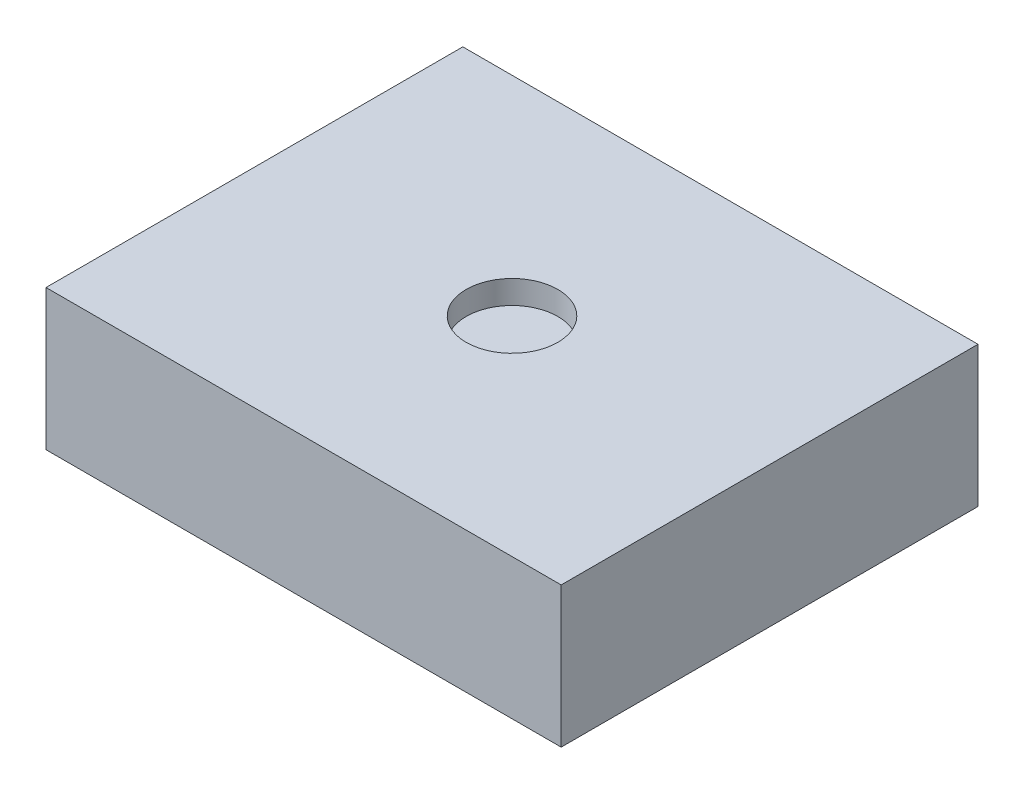
from build123d import *

# Parameters (mm, degrees)
SKETCH1_W           = 27.94
SKETCH1_H           = 22.606
BOSS_EXTRUDE1_DEPTH = 7.62
SKETCH2_R           = 2.486300295
CUT_EXTRUDE1_DEPTH  = 1.27


with BuildPart() as part:
    # Sketch1 → Boss-Extrude1 (new body)
    with BuildSketch(Plane(origin=(0, 0, 0), x_dir=(1, 0, 0), z_dir=(0, 1, 0))):
        Rectangle(SKETCH1_W, SKETCH1_H)
    extrude(amount=BOSS_EXTRUDE1_DEPTH)

    # Sketch2 → Cut-Extrude1 (cut)
    with BuildSketch(Plane(origin=(0, 7.62, 0), x_dir=(1, 0, 0), z_dir=(0, 1, 0))):
        Circle(SKETCH2_R)
    extrude(amount=-CUT_EXTRUDE1_DEPTH, mode=Mode.SUBTRACT)


solid = part.part
